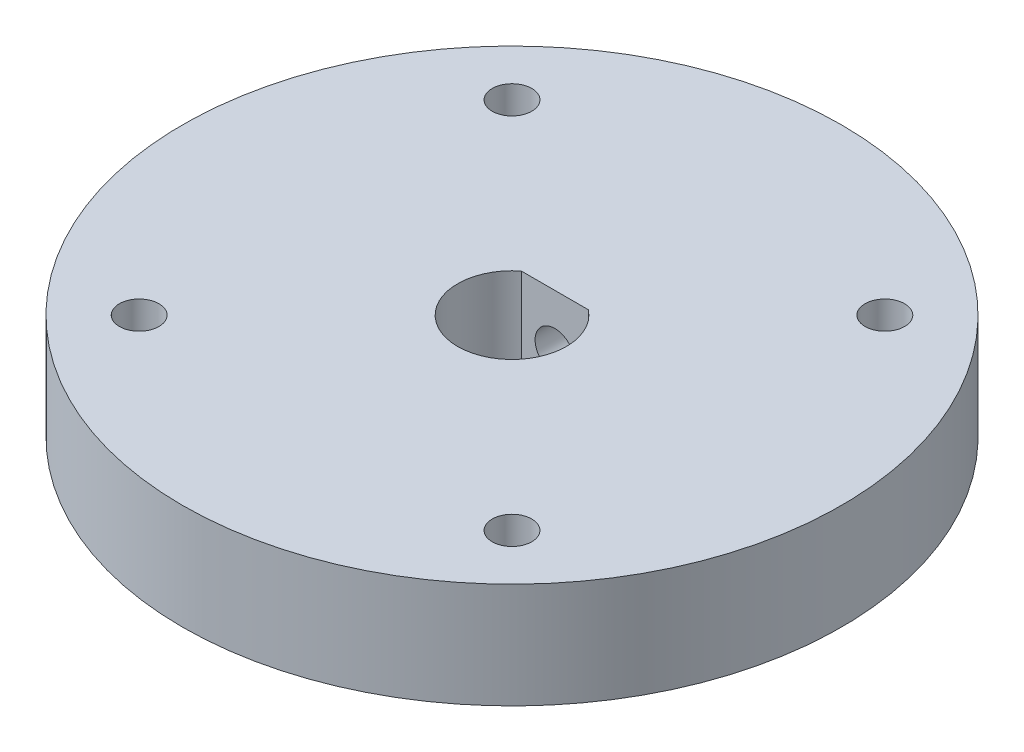
from build123d import *

# Parameters (mm, degrees)
SKETCH1_R               = 25
SKETCH1_R_2             = 1.5
BOSS_EXTRUDE1_DEPTH     = 8
SKETCH2_R               = 1.5
CUT_EXTRUDE1_DEPTH      = 35
SKETCH3_R               = 2.540300179
CUT_EXTRUDE3_DEPTH      = 2
CUT_EXTRUDE3_DEPTH_BACK = 35


with BuildPart() as part:
    # Sketch1 → Boss-Extrude1 (new body)
    with BuildSketch(Plane(origin=(0, 0, 0), x_dir=(1, 0, 0), z_dir=(0, 1, 0))):
        Circle(SKETCH1_R)
        with Locations((-14.142135624, -14.142135624)):
            Circle(SKETCH1_R_2, mode=Mode.SUBTRACT)
        with Locations((-14.142135624, 14.142135624)):
            Circle(SKETCH1_R_2, mode=Mode.SUBTRACT)
        with Locations((14.142135624, 14.142135624)):
            Circle(SKETCH1_R_2, mode=Mode.SUBTRACT)
        with Locations((14.142135624, -14.142135624)):
            Circle(SKETCH1_R_2, mode=Mode.SUBTRACT)
        with BuildLine():
            Line((2.540300179, 3.25), (-2.540300179, 3.25))
            ThreePointArc((-2.540300179, 3.25), (0, -4.125), (2.540300179, 3.25))
        make_face(mode=Mode.SUBTRACT)
    extrude(amount=BOSS_EXTRUDE1_DEPTH)

    # Sketch2 → Cut-Extrude1 (cut)
    with BuildSketch(Plane.XY.offset(-3.25)):
        with Locations((0, 4)):
            Circle(SKETCH2_R)
    extrude(amount=-CUT_EXTRUDE1_DEPTH, mode=Mode.SUBTRACT)

    # Sketch3 → Cut-Extrude3 (cut, two sides)
    with BuildSketch(Plane.XY.offset(-24)) as cut_extrude3_sk:
        with Locations((0, 4)):
            Circle(SKETCH3_R)
    extrude(amount=CUT_EXTRUDE3_DEPTH, mode=Mode.SUBTRACT)
    extrude(cut_extrude3_sk.sketch, amount=-CUT_EXTRUDE3_DEPTH_BACK, mode=Mode.SUBTRACT)


solid = part.part
